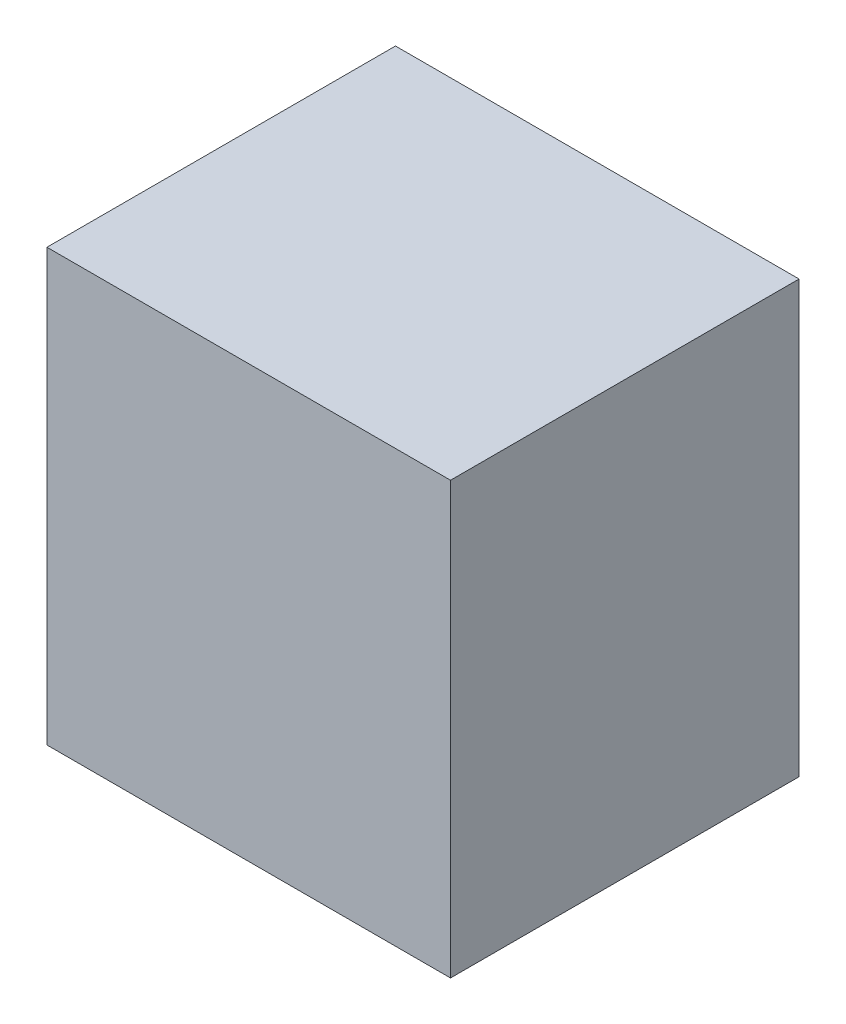
from build123d import *

# Parameters (mm, degrees)
SKETCH2_W           = 88
SKETCH2_H           = 76
BOSS_EXTRUDE1_DEPTH = 94


with BuildPart() as part:
    # Sketch2 → Boss-Extrude1 (new body)
    with BuildSketch(Plane(origin=(0, 0, 0), x_dir=(1, 0, 0), z_dir=(0, 1, 0))):
        with Locations((44, 38)):
            Rectangle(SKETCH2_W, SKETCH2_H)
    extrude(amount=BOSS_EXTRUDE1_DEPTH)


solid = part.part
